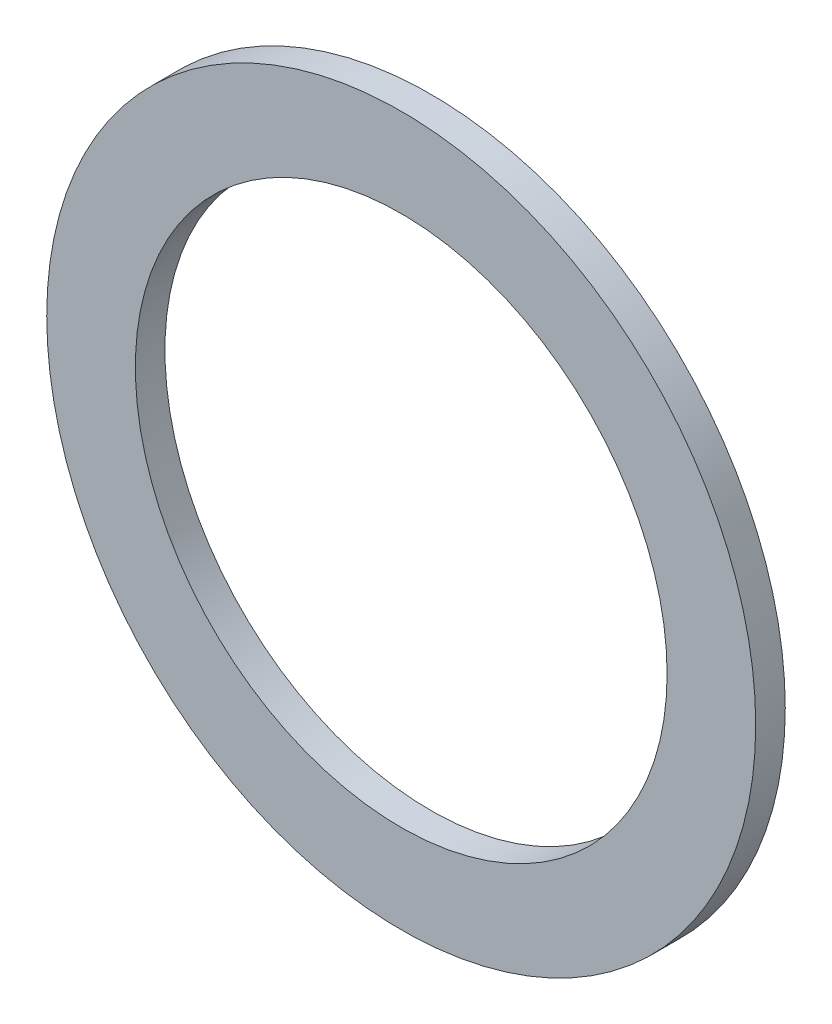
from build123d import *

# Parameters (mm, degrees)
SKETCH1_R           = 38.1
SKETCH1_R_2         = 28.575
BOSS_EXTRUDE1_DEPTH = 3.175


with BuildPart() as part:
    # Sketch1 → Boss-Extrude1 (new body)
    with BuildSketch(Plane.XY):
        Circle(SKETCH1_R)
        Circle(SKETCH1_R_2, mode=Mode.SUBTRACT)
    extrude(amount=BOSS_EXTRUDE1_DEPTH)


solid = part.part
